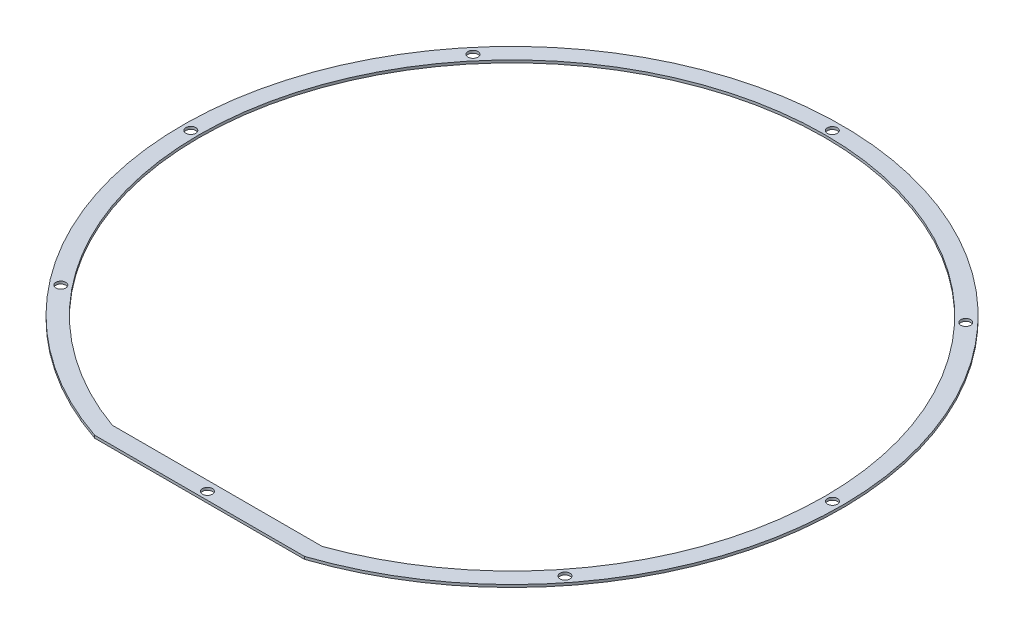
from build123d import *

# Parameters (mm, degrees)
THICKEN1_T1          = 0.625
M2_CLEARANCE_HOLE1_D = 2.4


with BuildPart() as body_1:
    # Sketch1 → Surface-Fill1: a flat surface bounded by the sketch
    with BuildSketch(Plane(origin=(0, 0, 0), x_dir=(1, 0, 0), z_dir=(0, 1, 0)), mode=Mode.PRIVATE) as surface_fill1_1_region:
        with BuildLine():
            Line((-25.4, -75.628621566), (25.4, -75.628621566))
            ThreePointArc((25.4, -75.628621566), (0, 79.78), (-25.4, -75.628621566))
        make_face()
        with BuildLine():
            Line((-25.4, -71.396417277), (25.4, -71.396417277))
            ThreePointArc((25.4, -71.396417277), (0, 75.78), (-25.4, -71.396417277))
        make_face(mode=Mode.SUBTRACT)
    surface_fill1_1 = surface_fill1_1_region.sketch.faces()[0]
    add(Solid.thicken(surface_fill1_1, THICKEN1_T1))

    # M2 Clearance Hole1 (through all)
    with Locations(Plane(origin=(0, 0.625, 0), x_dir=(1, 0, 0), z_dir=(0, 1, 0))):
        with Locations((0, 77.529954233), (0, -73.744874158), (77.744469628, -0.179745534), (-77.678576515, -0.083327834), (56.371935899, 53.45957237), (-59.482060021, 50.023142165), (61.035706748, -48.220860015), (-60.982517002, -48.258309848)):
            Hole(M2_CLEARANCE_HOLE1_D / 2)


solid = body_1.part
